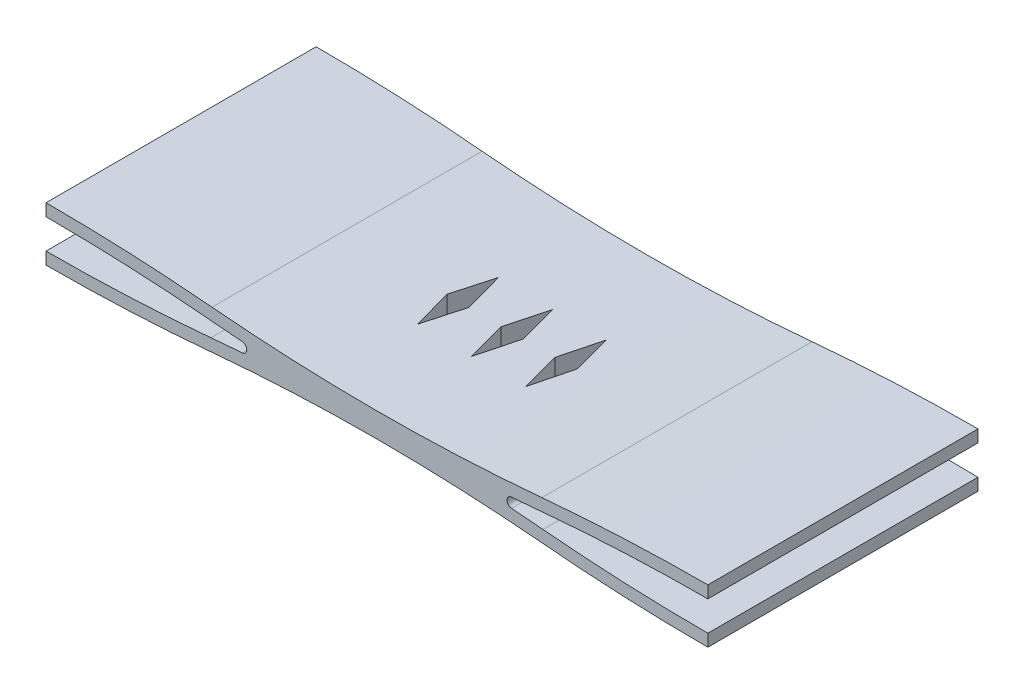
from build123d import *

# Parameters (mm, degrees)
BOSS_EXTRUDE1_DEPTH = 10
CUT_EXTRUDE1_DEPTH  = 16.844951877
LPATTERN1_COUNT     = 3
LPATTERN1_PITCH     = 2


with BuildPart() as part:
    # Sketch2 → Boss-Extrude1 (new body)
    with BuildSketch(Plane.XY):
        with BuildLine():
            Line((12.25, 1), (12.25, 0.55))
            ThreePointArc((12.25, 0.55), (9.194506694, 0.481441826), (6.145163436, 0.275905297))
            ThreePointArc((6.145163436, 0.275905297), (5.566162178, 0.226280663), (4.986761169, 0.181564549))
            ThreePointArc((4.986761169, 0.181564549), (4.817953434, 0), (4.986761169, -0.181564549))
            ThreePointArc((4.986761169, -0.181564549), (5.566162178, -0.226280663), (6.145163436, -0.275905297))
            ThreePointArc((6.145163436, -0.275905297), (9.194506694, -0.481441826), (12.25, -0.55))
            Line((12.25, -0.55), (12.25, -1))
            ThreePointArc((12.25, -1), (9.174322945, -0.93098895), (6.104836564, -0.724094703))
            ThreePointArc((6.104836564, -0.724094703), (3.055493306, -0.518558174), (0, -0.45))
            ThreePointArc((0, -0.45), (-3.055493306, -0.518558174), (-6.104836564, -0.724094703))
            ThreePointArc((-6.104836564, -0.724094703), (-9.174322945, -0.93098895), (-12.25, -1))
            Line((-12.25, -1), (-12.25, -0.55))
            ThreePointArc((-12.25, -0.55), (-9.194506694, -0.481441826), (-6.145163436, -0.275905297))
            ThreePointArc((-6.145163436, -0.275905297), (-5.566162178, -0.226280663), (-4.986761169, -0.181564549))
            ThreePointArc((-4.986761169, -0.181564549), (-4.817953434, 0), (-4.986761169, 0.181564549))
            ThreePointArc((-4.986761169, 0.181564549), (-5.566162178, 0.226280663), (-6.145163436, 0.275905297))
            ThreePointArc((-6.145163436, 0.275905297), (-9.194506694, 0.481441826), (-12.25, 0.55))
            Line((-12.25, 0.55), (-12.25, 1))
            ThreePointArc((-12.25, 1), (-9.174322945, 0.93098895), (-6.104836564, 0.724094703))
            ThreePointArc((-6.104836564, 0.724094703), (-3.055493306, 0.518558174), (0, 0.45))
            ThreePointArc((0, 0.45), (3.055493306, 0.518558174), (6.104836564, 0.724094703))
            ThreePointArc((6.104836564, 0.724094703), (9.174322945, 0.93098895), (12.25, 1))
        make_face()
    extrude(amount=BOSS_EXTRUDE1_DEPTH)

    # Sketch3 → Cut-Extrude1 (cut, symmetric)
    with BuildSketch(Plane(origin=(0, 0, 0), x_dir=(1, 0, 0), z_dir=(0, 1, 0))):
        Polygon((-2, -3.5), (-1.598076211, -5), (-2, -6.5), (-2.401923789, -5), align=None)
    cut_extrude1 = extrude(amount=CUT_EXTRUDE1_DEPTH, both=True, mode=Mode.SUBTRACT)

    # LPattern1: Cut-Extrude1 ×3
    with Locations(*[(i * LPATTERN1_PITCH, 0, 0) for i in range(1, LPATTERN1_COUNT)]):
        add(cut_extrude1, mode=Mode.SUBTRACT)


solid = part.part
